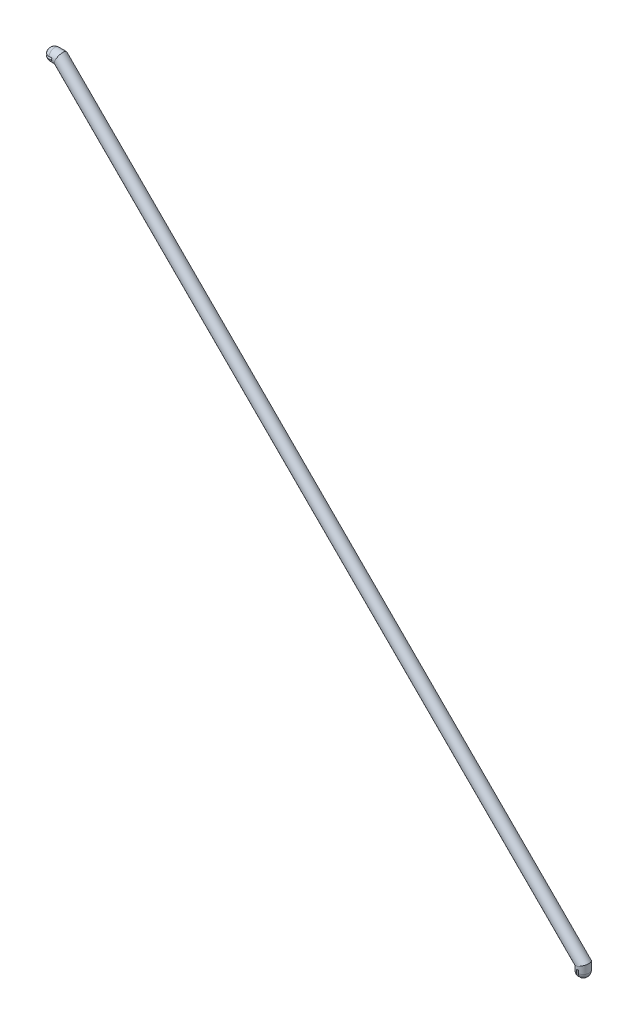
from build123d import *

# Parameters (mm, degrees)
SKETCH2_R          = 4
REVOLVE7_ANGLE     = 180
CUT_EXTRUDE1_START = -2
SKETCH6_W          = 1.5
SKETCH6_H          = 8
CUT_EXTRUDE1_DEPTH = 12
SKETCH8_R          = 0.75
CUT_EXTRUDE2_DEPTH = 1.5


with BuildPart() as part:
    # Sweep1: sweep along a path in Sketch1
    with BuildLine(Plane.XY) as sweep1_path:
        Line((-181.381279793, 177.381279793), (-177.381279793, 177.381279793))
        Line((-177.381279793, 177.381279793), (177.381279793, -177.381279793))
        Line((177.381279793, -177.381279793), (177.381279793, -181.381279793))
    # Sketch2 → Sweep1 (sweep)
    with BuildSketch(Plane(origin=(0, 0, 0), x_dir=(0, 0, 1), z_dir=(-0.707106781, 0.707106781, 0))):
        Circle(SKETCH2_R)
    sweep(path=sweep1_path.line, transition=Transition.RIGHT)

    # Sketch4 → Revolve7 (revolve)
    with BuildSketch(Plane.XZ.offset(181.381279793)):
        with BuildLine():
            Line((177.381279793, 4), (177.381279793, -4))
            ThreePointArc((177.381279793, -4), (181.381279793, 0), (177.381279793, 4))
        make_face()
    revolve7 = revolve(axis=Axis((177.381279793, -181.381279793, 4), (0, 0, -1)), revolution_arc=REVOLVE7_ANGLE)

    # Sketch6 → Cut-Extrude1 (cut)
    with BuildSketch(Plane(origin=(0, -181.381279793, 0), x_dir=(-1, 0, 0), z_dir=(0, -1, 0)).offset(CUT_EXTRUDE1_START)):
        with Locations((-177.381279793, 0)):
            Rectangle(SKETCH6_W, SKETCH6_H)
    cut_extrude1 = extrude(amount=CUT_EXTRUDE1_DEPTH, mode=Mode.SUBTRACT)

    # Sketch8 → Cut-Extrude2 (cut, symmetric)
    with BuildSketch(Plane(origin=(177.381279793, 0, 0), x_dir=(0, 0, -1), z_dir=(1, 0, 0))):
        with Locations((0, -182.310338204)):
            Circle(SKETCH8_R)
    cut_extrude2 = extrude(amount=CUT_EXTRUDE2_DEPTH, both=True, mode=Mode.SUBTRACT)

    # Mirror1: Revolve7, Cut-Extrude1, Cut-Extrude2 across plane
    add(revolve7.mirror(Plane(origin=(0, 0, 0), x_dir=(0, 0, 1), z_dir=(-0.707106781, 0.707106781, 0))))
    add(cut_extrude1.mirror(Plane(origin=(0, 0, 0), x_dir=(0, 0, 1), z_dir=(-0.707106781, 0.707106781, 0))), mode=Mode.SUBTRACT)
    add(cut_extrude2.mirror(Plane(origin=(0, 0, 0), x_dir=(0, 0, 1), z_dir=(-0.707106781, 0.707106781, 0))), mode=Mode.SUBTRACT)


solid = part.part
